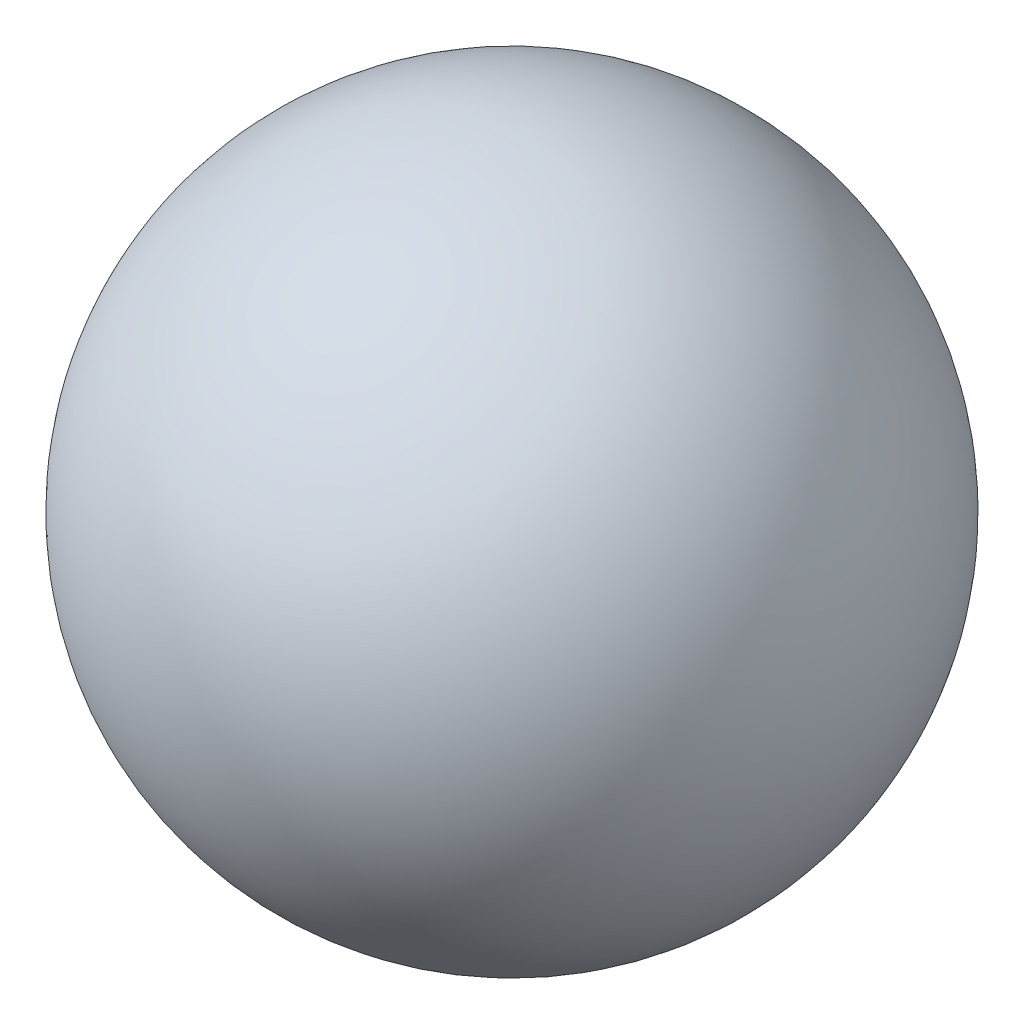
from build123d import *


with BuildPart() as part:
    # Sketch1 → Revolve1 (revolve)
    with BuildSketch(Plane.XY):
        with BuildLine():
            Line((-12, 0), (12, 0))
            ThreePointArc((12, 0), (0, -12), (-12, 0))
        make_face()
    revolve(axis=Axis((-12, 0, 0), (1, 0, 0)))


solid = part.part
